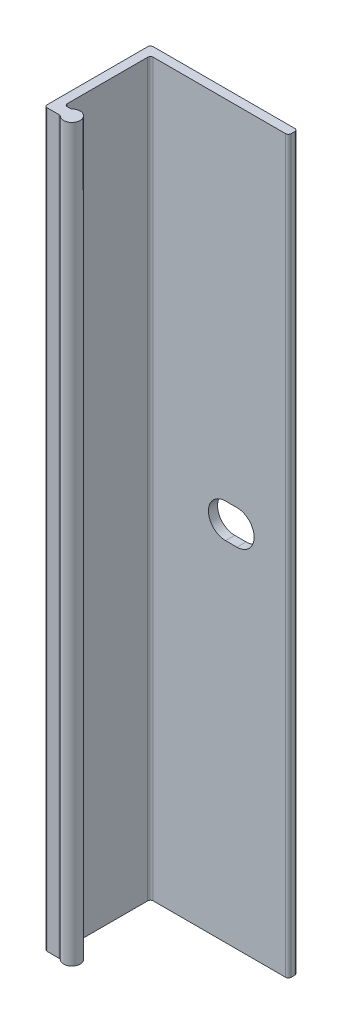
from build123d import *

# Parameters (mm, degrees)
BOSS_EXTRUDE1_DEPTH = 50.8
CUT_EXTRUDE1_DEPTH  = 2.27


with BuildPart() as part:
    # Sketch2 → Boss-Extrude1 (new body, symmetric)
    with BuildSketch(Plane(origin=(0, 0, 0), x_dir=(1, 0, 0), z_dir=(0, 1, 0))):
        with BuildLine():
            Line((0.381, 0), (20.066, 0))
            ThreePointArc((20.066, 0), (20.335407684, -0.111592316), (20.447, -0.381))
            Line((20.447, -0.381), (20.447, -0.889))
            ThreePointArc((20.447, -0.889), (20.335407684, -1.158407684), (20.066, -1.27))
            Line((20.066, -1.27), (1.651, -1.27))
            ThreePointArc((1.651, -1.27), (1.381592316, -1.381592316), (1.27, -1.651))
            Line((1.27, -1.651), (1.27, -12.827))
            ThreePointArc((1.27, -12.827), (1.381592316, -13.096407684), (1.651, -13.208))
            Line((1.651, -13.208), (2.03996875, -13.208))
            ThreePointArc((2.03996875, -13.208), (2.174672592, -13.183392866), (2.291976563, -13.11275))
            ThreePointArc((2.291976563, -13.11275), (4.191, -13.97), (2.291976563, -14.82725))
            ThreePointArc((2.291976563, -14.82725), (2.174672592, -14.756607134), (2.03996875, -14.732))
            Line((2.03996875, -14.732), (0.381, -14.732))
            ThreePointArc((0.381, -14.732), (0.111592316, -14.620407684), (0, -14.351))
            Line((0, -14.351), (0, -0.381))
            ThreePointArc((0, -0.381), (0.111592316, -0.111592316), (0.381, 0))
        make_face()
    extrude(amount=BOSS_EXTRUDE1_DEPTH, both=True)

    # Sketch7 → Cut-Extrude1 (cut, through all)
    with BuildSketch(Plane.XY.offset(1.27)):
        with BuildLine():
            Line((11.71575, 2.38125), (13.30325, 2.38125))
            ThreePointArc((13.30325, 2.38125), (15.6845, 0), (13.30325, -2.38125))
            Line((13.30325, -2.38125), (11.71575, -2.38125))
            ThreePointArc((11.71575, -2.38125), (9.3345, 0), (11.71575, 2.38125))
        make_face()
    extrude(amount=-CUT_EXTRUDE1_DEPTH, mode=Mode.SUBTRACT)


solid = part.part
